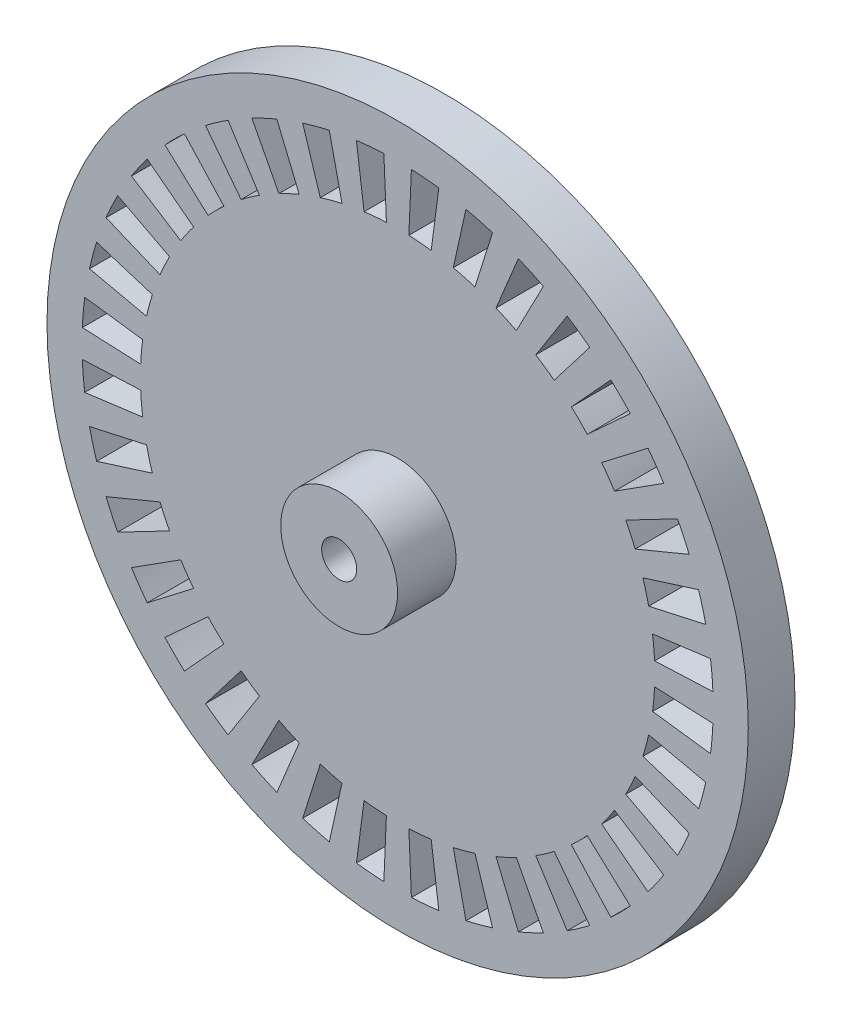
from build123d import *

# Parameters (mm, degrees)
ESQUISSE1_R        = 30
ESQUISSE1_R_2      = 1.5
BOSS_EXTRU_1_DEPTH = 4
ESQUISSE2_R        = 5
ESQUISSE2_R_2      = 1.5
BOSS_EXTRU_2_DEPTH = 5


with BuildPart() as part:
    # Esquisse1 → Boss.-Extru.1 (new body)
    with BuildSketch(Plane.XY):
        Circle(ESQUISSE1_R)
        with BuildLine():
            Line((-26.974301983, -1.177723459), (-21.979060875, -0.959626522))
            ThreePointArc((-21.979060875, -0.959626522), (-21.916283358, -1.91742634), (-21.81178695, -2.871576229))
            Line((-21.81178695, -2.871576229), (-26.769011257, -3.52420719))
            ThreePointArc((-26.769011257, -3.52420719), (-26.897256848, -2.353205054), (-26.974301983, -1.177723459))
        make_face(mode=Mode.SUBTRACT)
        with BuildLine():
            Line((-26.359992192, -5.843869576), (-21.478512157, -4.761671507))
            ThreePointArc((-21.478512157, -4.761671507), (-21.250368178, -5.694018992), (-20.981772916, -6.615527589))
            Line((-20.981772916, -6.615527589), (-25.75035767, -8.119056587))
            ThreePointArc((-25.75035767, -8.119056587), (-26.07999731, -6.988114218), (-26.359992192, -5.843869576))
        make_face(mode=Mode.SUBTRACT)
        with BuildLine():
            Line((-24.944747378, -10.332452674), (-20.325349715, -8.419035512))
            ThreePointArc((-20.325349715, -8.419035512), (-19.938771315, -9.297601758), (-19.51423833, -10.158469491))
            Line((-19.51423833, -10.158469491), (-23.949292496, -12.467212557))
            ThreePointArc((-23.949292496, -12.467212557), (-24.47031025, -11.410693067), (-24.944747378, -10.332452674))
        make_face(mode=Mode.SUBTRACT)
        with BuildLine():
            Line((-22.771569037, -14.507089425), (-18.554611808, -11.820591384))
            ThreePointArc((-18.554611808, -11.820591384), (-18.021344974, -12.6186816), (-17.453773486, -13.392751438))
            Line((-17.453773486, -13.392751438), (-21.420540188, -16.436558583))
            ThreePointArc((-21.420540188, -16.436558583), (-22.117105196, -15.486563781), (-22.771569037, -14.507089425))
        make_face(mode=Mode.SUBTRACT)
        with BuildLine():
            Line((-19.906488094, -18.240935606), (-16.22010141, -14.862984568))
            ThreePointArc((-16.22010141, -14.862984568), (-15.556349186, -15.556349186), (-14.862984568, -16.22010141))
            Line((-14.862984568, -16.22010141), (-18.240935606, -19.906488094))
            ThreePointArc((-18.240935606, -19.906488094), (-19.091883092, -19.091883092), (-19.906488094, -18.240935606))
        make_face(mode=Mode.SUBTRACT)
        with BuildLine():
            Line((-16.436558583, -21.420540188), (-13.392751438, -17.453773486))
            ThreePointArc((-13.392751438, -17.453773486), (-12.6186816, -18.021344974), (-11.820591384, -18.554611808))
            Line((-11.820591384, -18.554611808), (-14.507089425, -22.771569037))
            ThreePointArc((-14.507089425, -22.771569037), (-15.486563781, -22.117105196), (-16.436558583, -21.420540188))
        make_face(mode=Mode.SUBTRACT)
        with BuildLine():
            Line((-12.467212557, -23.949292496), (-10.158469491, -19.51423833))
            ThreePointArc((-10.158469491, -19.51423833), (-9.297601758, -19.938771315), (-8.419035512, -20.325349715))
            Line((-8.419035512, -20.325349715), (-10.332452674, -24.944747378))
            ThreePointArc((-10.332452674, -24.944747378), (-11.410693067, -24.47031025), (-12.467212557, -23.949292496))
        make_face(mode=Mode.SUBTRACT)
        with BuildLine():
            Line((-8.119056587, -25.75035767), (-6.615527589, -20.981772916))
            ThreePointArc((-6.615527589, -20.981772916), (-5.694018992, -21.250368178), (-4.761671507, -21.478512157))
            Line((-4.761671507, -21.478512157), (-5.843869576, -26.359992192))
            ThreePointArc((-5.843869576, -26.359992192), (-6.988114218, -26.07999731), (-8.119056587, -25.75035767))
        make_face(mode=Mode.SUBTRACT)
        with BuildLine():
            Line((-3.52420719, -26.769011257), (-2.871576229, -21.81178695))
            ThreePointArc((-2.871576229, -21.81178695), (-1.91742634, -21.916283358), (-0.959626522, -21.979060875))
            Line((-0.959626522, -21.979060875), (-1.177723459, -26.974301983))
            ThreePointArc((-1.177723459, -26.974301983), (-2.353205054, -26.897256848), (-3.52420719, -26.769011257))
        make_face(mode=Mode.SUBTRACT)
        with BuildLine():
            Line((1.177723459, -26.974301983), (0.959626522, -21.979060875))
            ThreePointArc((0.959626522, -21.979060875), (1.91742634, -21.916283358), (2.871576229, -21.81178695))
            Line((2.871576229, -21.81178695), (3.52420719, -26.769011257))
            ThreePointArc((3.52420719, -26.769011257), (2.353205054, -26.897256848), (1.177723459, -26.974301983))
        make_face(mode=Mode.SUBTRACT)
        with BuildLine():
            Line((5.843869576, -26.359992192), (4.761671507, -21.478512157))
            ThreePointArc((4.761671507, -21.478512157), (5.694018992, -21.250368178), (6.615527589, -20.981772916))
            Line((6.615527589, -20.981772916), (8.119056587, -25.75035767))
            ThreePointArc((8.119056587, -25.75035767), (6.988114218, -26.07999731), (5.843869576, -26.359992192))
        make_face(mode=Mode.SUBTRACT)
        with BuildLine():
            Line((10.332452674, -24.944747378), (8.419035512, -20.325349715))
            ThreePointArc((8.419035512, -20.325349715), (9.297601758, -19.938771315), (10.158469491, -19.51423833))
            Line((10.158469491, -19.51423833), (12.467212557, -23.949292496))
            ThreePointArc((12.467212557, -23.949292496), (11.410693067, -24.47031025), (10.332452674, -24.944747378))
        make_face(mode=Mode.SUBTRACT)
        with BuildLine():
            Line((14.507089425, -22.771569037), (11.820591384, -18.554611808))
            ThreePointArc((11.820591384, -18.554611808), (12.6186816, -18.021344974), (13.392751438, -17.453773486))
            Line((13.392751438, -17.453773486), (16.436558583, -21.420540188))
            ThreePointArc((16.436558583, -21.420540188), (15.486563781, -22.117105196), (14.507089425, -22.771569037))
        make_face(mode=Mode.SUBTRACT)
        with BuildLine():
            Line((18.240935606, -19.906488094), (14.862984568, -16.22010141))
            ThreePointArc((14.862984568, -16.22010141), (15.556349186, -15.556349186), (16.22010141, -14.862984568))
            Line((16.22010141, -14.862984568), (19.906488094, -18.240935606))
            ThreePointArc((19.906488094, -18.240935606), (19.091883092, -19.091883092), (18.240935606, -19.906488094))
        make_face(mode=Mode.SUBTRACT)
        with BuildLine():
            Line((21.420540188, -16.436558583), (17.453773486, -13.392751438))
            ThreePointArc((17.453773486, -13.392751438), (18.021344974, -12.6186816), (18.554611808, -11.820591384))
            Line((18.554611808, -11.820591384), (22.771569037, -14.507089425))
            ThreePointArc((22.771569037, -14.507089425), (22.117105196, -15.486563781), (21.420540188, -16.436558583))
        make_face(mode=Mode.SUBTRACT)
        with BuildLine():
            Line((23.949292496, -12.467212557), (19.51423833, -10.158469491))
            ThreePointArc((19.51423833, -10.158469491), (19.938771315, -9.297601758), (20.325349715, -8.419035512))
            Line((20.325349715, -8.419035512), (24.944747378, -10.332452674))
            ThreePointArc((24.944747378, -10.332452674), (24.47031025, -11.410693067), (23.949292496, -12.467212557))
        make_face(mode=Mode.SUBTRACT)
        with BuildLine():
            Line((25.75035767, -8.119056587), (20.981772916, -6.615527589))
            ThreePointArc((20.981772916, -6.615527589), (21.250368178, -5.694018992), (21.478512157, -4.761671507))
            Line((21.478512157, -4.761671507), (26.359992192, -5.843869576))
            ThreePointArc((26.359992192, -5.843869576), (26.07999731, -6.988114218), (25.75035767, -8.119056587))
        make_face(mode=Mode.SUBTRACT)
        with BuildLine():
            Line((26.769011257, -3.52420719), (21.81178695, -2.871576229))
            ThreePointArc((21.81178695, -2.871576229), (21.916283358, -1.91742634), (21.979060875, -0.959626522))
            Line((21.979060875, -0.959626522), (26.974301983, -1.177723459))
            ThreePointArc((26.974301983, -1.177723459), (26.897256848, -2.353205054), (26.769011257, -3.52420719))
        make_face(mode=Mode.SUBTRACT)
        with BuildLine():
            Line((26.974301983, 1.177723459), (21.979060875, 0.959626522))
            ThreePointArc((21.979060875, 0.959626522), (21.916283358, 1.91742634), (21.81178695, 2.871576229))
            Line((21.81178695, 2.871576229), (26.769011257, 3.52420719))
            ThreePointArc((26.769011257, 3.52420719), (26.897256848, 2.353205054), (26.974301983, 1.177723459))
        make_face(mode=Mode.SUBTRACT)
        with BuildLine():
            Line((26.359992192, 5.843869576), (21.478512157, 4.761671507))
            ThreePointArc((21.478512157, 4.761671507), (21.250368178, 5.694018992), (20.981772916, 6.615527589))
            Line((20.981772916, 6.615527589), (25.75035767, 8.119056587))
            ThreePointArc((25.75035767, 8.119056587), (26.07999731, 6.988114218), (26.359992192, 5.843869576))
        make_face(mode=Mode.SUBTRACT)
        with BuildLine():
            Line((24.944747378, 10.332452674), (20.325349715, 8.419035512))
            ThreePointArc((20.325349715, 8.419035512), (19.938771315, 9.297601758), (19.51423833, 10.158469491))
            Line((19.51423833, 10.158469491), (23.949292496, 12.467212557))
            ThreePointArc((23.949292496, 12.467212557), (24.47031025, 11.410693067), (24.944747378, 10.332452674))
        make_face(mode=Mode.SUBTRACT)
        with BuildLine():
            Line((22.771569037, 14.507089425), (18.554611808, 11.820591384))
            ThreePointArc((18.554611808, 11.820591384), (18.021344974, 12.6186816), (17.453773486, 13.392751438))
            Line((17.453773486, 13.392751438), (21.420540188, 16.436558583))
            ThreePointArc((21.420540188, 16.436558583), (22.117105196, 15.486563781), (22.771569037, 14.507089425))
        make_face(mode=Mode.SUBTRACT)
        with BuildLine():
            Line((19.906488094, 18.240935606), (16.22010141, 14.862984568))
            ThreePointArc((16.22010141, 14.862984568), (15.556349186, 15.556349186), (14.862984568, 16.22010141))
            Line((14.862984568, 16.22010141), (18.240935606, 19.906488094))
            ThreePointArc((18.240935606, 19.906488094), (19.091883092, 19.091883092), (19.906488094, 18.240935606))
        make_face(mode=Mode.SUBTRACT)
        with BuildLine():
            Line((16.436558583, 21.420540188), (13.392751438, 17.453773486))
            ThreePointArc((13.392751438, 17.453773486), (12.6186816, 18.021344974), (11.820591384, 18.554611808))
            Line((11.820591384, 18.554611808), (14.507089425, 22.771569037))
            ThreePointArc((14.507089425, 22.771569037), (15.486563781, 22.117105196), (16.436558583, 21.420540188))
        make_face(mode=Mode.SUBTRACT)
        with BuildLine():
            Line((12.467212557, 23.949292496), (10.158469491, 19.51423833))
            ThreePointArc((10.158469491, 19.51423833), (9.297601758, 19.938771315), (8.419035512, 20.325349715))
            Line((8.419035512, 20.325349715), (10.332452674, 24.944747378))
            ThreePointArc((10.332452674, 24.944747378), (11.410693067, 24.47031025), (12.467212557, 23.949292496))
        make_face(mode=Mode.SUBTRACT)
        with BuildLine():
            Line((8.119056587, 25.75035767), (6.615527589, 20.981772916))
            ThreePointArc((6.615527589, 20.981772916), (5.694018992, 21.250368178), (4.761671507, 21.478512157))
            Line((4.761671507, 21.478512157), (5.843869576, 26.359992192))
            ThreePointArc((5.843869576, 26.359992192), (6.988114218, 26.07999731), (8.119056587, 25.75035767))
        make_face(mode=Mode.SUBTRACT)
        with BuildLine():
            Line((3.52420719, 26.769011257), (2.871576229, 21.81178695))
            ThreePointArc((2.871576229, 21.81178695), (1.91742634, 21.916283358), (0.959626522, 21.979060875))
            Line((0.959626522, 21.979060875), (1.177723459, 26.974301983))
            ThreePointArc((1.177723459, 26.974301983), (2.353205054, 26.897256848), (3.52420719, 26.769011257))
        make_face(mode=Mode.SUBTRACT)
        with BuildLine():
            Line((-1.177723459, 26.974301983), (-0.959626522, 21.979060875))
            ThreePointArc((-0.959626522, 21.979060875), (-1.91742634, 21.916283358), (-2.871576229, 21.81178695))
            Line((-2.871576229, 21.81178695), (-3.52420719, 26.769011257))
            ThreePointArc((-3.52420719, 26.769011257), (-2.353205054, 26.897256848), (-1.177723459, 26.974301983))
        make_face(mode=Mode.SUBTRACT)
        with BuildLine():
            Line((-5.843869576, 26.359992192), (-4.761671507, 21.478512157))
            ThreePointArc((-4.761671507, 21.478512157), (-5.694018992, 21.250368178), (-6.615527589, 20.981772916))
            Line((-6.615527589, 20.981772916), (-8.119056587, 25.75035767))
            ThreePointArc((-8.119056587, 25.75035767), (-6.988114218, 26.07999731), (-5.843869576, 26.359992192))
        make_face(mode=Mode.SUBTRACT)
        with BuildLine():
            Line((-10.332452674, 24.944747378), (-8.419035512, 20.325349715))
            ThreePointArc((-8.419035512, 20.325349715), (-9.297601758, 19.938771315), (-10.158469491, 19.51423833))
            Line((-10.158469491, 19.51423833), (-12.467212557, 23.949292496))
            ThreePointArc((-12.467212557, 23.949292496), (-11.410693067, 24.47031025), (-10.332452674, 24.944747378))
        make_face(mode=Mode.SUBTRACT)
        with BuildLine():
            Line((-14.507089425, 22.771569037), (-11.820591384, 18.554611808))
            ThreePointArc((-11.820591384, 18.554611808), (-12.6186816, 18.021344974), (-13.392751438, 17.453773486))
            Line((-13.392751438, 17.453773486), (-16.436558583, 21.420540188))
            ThreePointArc((-16.436558583, 21.420540188), (-15.486563781, 22.117105196), (-14.507089425, 22.771569037))
        make_face(mode=Mode.SUBTRACT)
        with BuildLine():
            Line((-18.240935606, 19.906488094), (-14.862984568, 16.22010141))
            ThreePointArc((-14.862984568, 16.22010141), (-15.556349186, 15.556349186), (-16.22010141, 14.862984568))
            Line((-16.22010141, 14.862984568), (-19.906488094, 18.240935606))
            ThreePointArc((-19.906488094, 18.240935606), (-19.091883092, 19.091883092), (-18.240935606, 19.906488094))
        make_face(mode=Mode.SUBTRACT)
        with BuildLine():
            Line((-21.420540188, 16.436558583), (-17.453773486, 13.392751438))
            ThreePointArc((-17.453773486, 13.392751438), (-18.021344974, 12.6186816), (-18.554611808, 11.820591384))
            Line((-18.554611808, 11.820591384), (-22.771569037, 14.507089425))
            ThreePointArc((-22.771569037, 14.507089425), (-22.117105196, 15.486563781), (-21.420540188, 16.436558583))
        make_face(mode=Mode.SUBTRACT)
        with BuildLine():
            Line((-23.949292496, 12.467212557), (-19.51423833, 10.158469491))
            ThreePointArc((-19.51423833, 10.158469491), (-19.938771315, 9.297601758), (-20.325349715, 8.419035512))
            Line((-20.325349715, 8.419035512), (-24.944747378, 10.332452674))
            ThreePointArc((-24.944747378, 10.332452674), (-24.47031025, 11.410693067), (-23.949292496, 12.467212557))
        make_face(mode=Mode.SUBTRACT)
        with BuildLine():
            Line((-25.75035767, 8.119056587), (-20.981772916, 6.615527589))
            ThreePointArc((-20.981772916, 6.615527589), (-21.250368178, 5.694018992), (-21.478512157, 4.761671507))
            Line((-21.478512157, 4.761671507), (-26.359992192, 5.843869576))
            ThreePointArc((-26.359992192, 5.843869576), (-26.07999731, 6.988114218), (-25.75035767, 8.119056587))
        make_face(mode=Mode.SUBTRACT)
        with BuildLine():
            Line((-26.769011257, 3.52420719), (-21.81178695, 2.871576229))
            ThreePointArc((-21.81178695, 2.871576229), (-21.916283358, 1.91742634), (-21.979060875, 0.959626522))
            Line((-21.979060875, 0.959626522), (-26.974301983, 1.177723459))
            ThreePointArc((-26.974301983, 1.177723459), (-26.897256848, 2.353205054), (-26.769011257, 3.52420719))
        make_face(mode=Mode.SUBTRACT)
        Circle(ESQUISSE1_R_2, mode=Mode.SUBTRACT)
    extrude(amount=BOSS_EXTRU_1_DEPTH)

    # Esquisse2 → Boss.-Extru.2 (add)
    with BuildSketch(Plane.XY.offset(4)):
        Circle(ESQUISSE2_R)
        Circle(ESQUISSE2_R_2, mode=Mode.SUBTRACT)
    extrude(amount=BOSS_EXTRU_2_DEPTH)


solid = part.part
